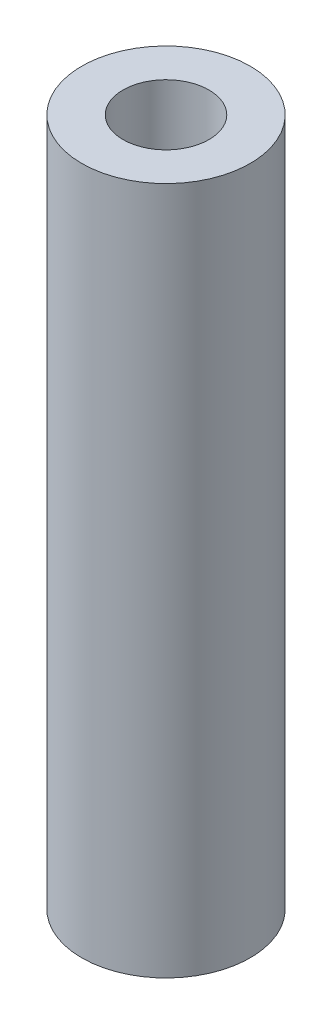
from build123d import *

# Parameters (mm, degrees)
SKETCH1_R           = 3.1115
SKETCH1_R_2         = 1.5875
BOSS_EXTRUDE1_DEPTH = 25.4


with BuildPart() as part:
    # Sketch1 → Boss-Extrude1 (new body)
    with BuildSketch(Plane(origin=(0, 0, 0), x_dir=(1, 0, 0), z_dir=(0, 1, 0))):
        Circle(SKETCH1_R)
        Circle(SKETCH1_R_2, mode=Mode.SUBTRACT)
    extrude(amount=BOSS_EXTRUDE1_DEPTH)


solid = part.part
